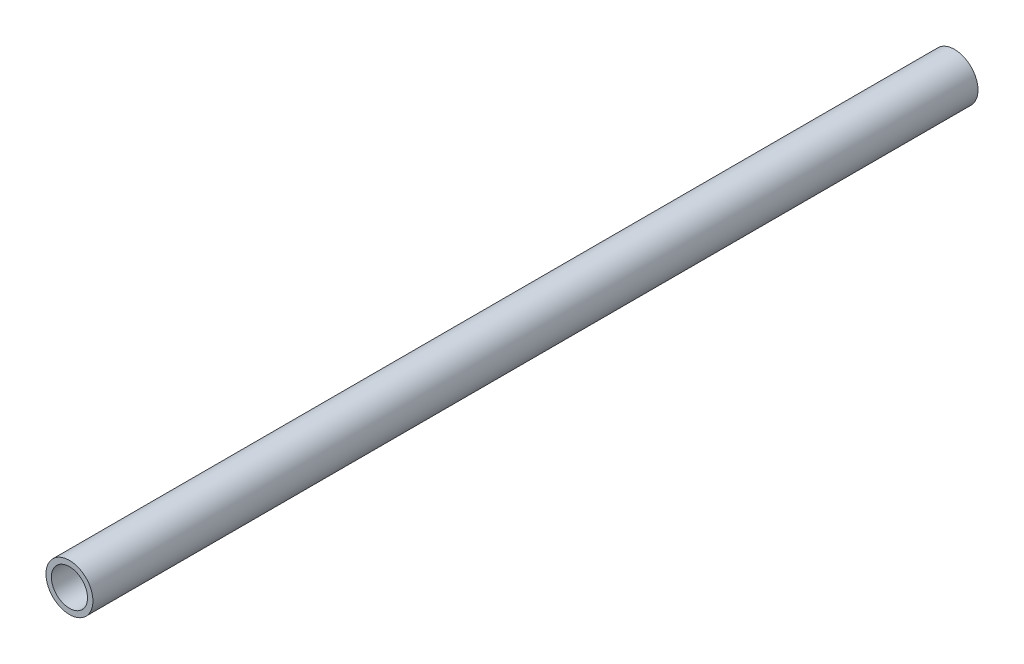
from build123d import *

# Parameters (mm, degrees)
SKETCH1_R           = 6.5
SKETCH1_R_2         = 5
EXTRUDE_THIN1_DEPTH = 245


with BuildPart() as part:
    # Sketch1 → Extrude-Thin1 (new body)
    with BuildSketch(Plane.XY):
        Circle(SKETCH1_R)
        Circle(SKETCH1_R_2, mode=Mode.SUBTRACT)
    extrude(amount=EXTRUDE_THIN1_DEPTH)


solid = part.part
